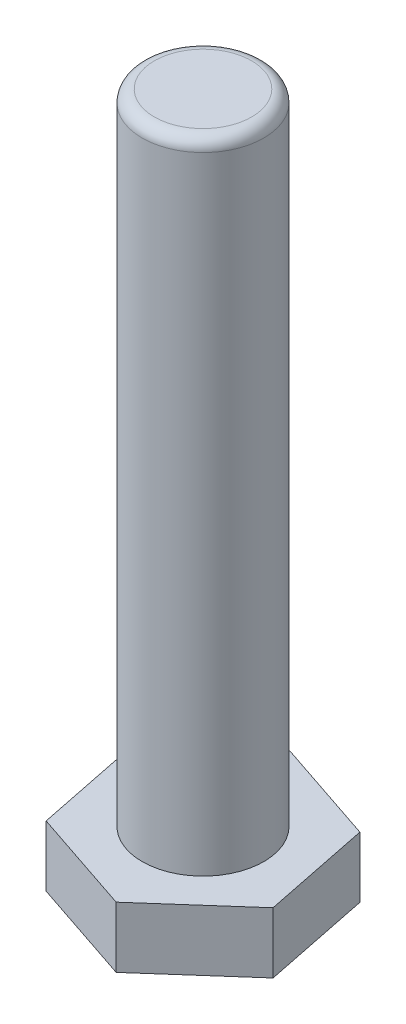
from build123d import *

# Parameters (mm, degrees)
BOSS_EXTRU_1_DEPTH = 10
ESQUISSE2_R        = 10
BOSS_EXTRU_2_DEPTH = 105
CONG_1_R           = 2


with BuildPart() as part:
    # Esquisse1 → Boss.-Extru.1 (new body)
    with BuildSketch(Plane(origin=(0, 0, 0), x_dir=(1, 0, 0), z_dir=(0, 1, 0))):
        Polygon((-13.68952605, -12.09634845), (3.630982025, -17.90365155), (17.320508076, -5.807303101), (13.68952605, 12.09634845), (-3.630982025, 17.90365155), (-17.320508076, 5.807303101), align=None)
    extrude(amount=BOSS_EXTRU_1_DEPTH)

    # Esquisse2 → Boss.-Extru.2 (add)
    with BuildSketch(Plane(origin=(0, 10, 0), x_dir=(1, 0, 0), z_dir=(0, 1, 0))):
        Circle(ESQUISSE2_R)
    extrude(amount=BOSS_EXTRU_2_DEPTH)

    # Congé1
    cong_1_edges = [part.edges().sort_by_distance(p)[0] for p in [
        (-10, 115, 0),
    ]]
    fillet(cong_1_edges, radius=CONG_1_R)


solid = part.part
